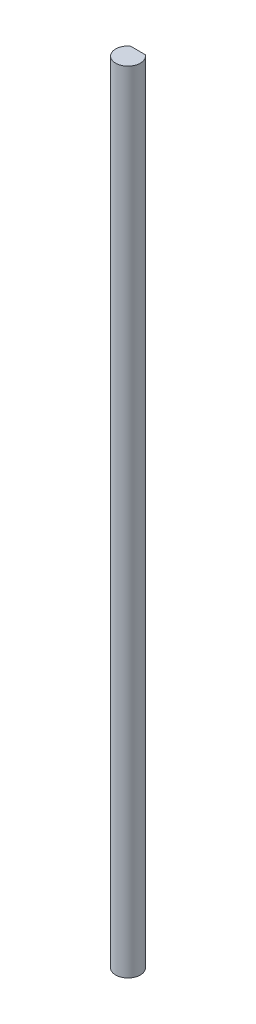
from build123d import *

# Parameters (mm, degrees)
BOSS_EXTRUDE1_DEPTH = 203.2


with BuildPart() as part:
    # Sketch1 → Boss-Extrude1 (new body)
    with BuildSketch(Plane(origin=(0, 0, 0), x_dir=(1, 0, 0), z_dir=(0, 1, 0))):
        with BuildLine():
            Line((-1.905, 2.54), (1.905, 2.54))
            ThreePointArc((1.905, 2.54), (0, -3.175), (-1.905, 2.54))
        make_face()
    extrude(amount=BOSS_EXTRUDE1_DEPTH)


solid = part.part
